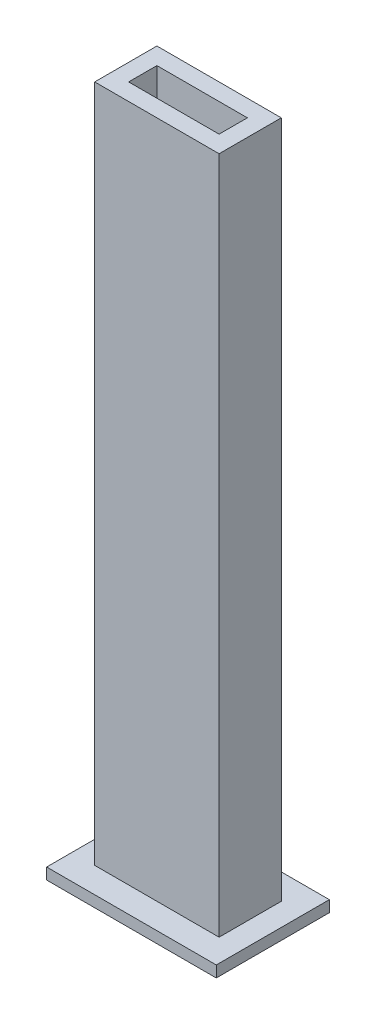
from build123d import *

# Parameters (mm, degrees)
CROQUIS1_W              = 30
CROQUIS1_H              = 20
SALIENTE_EXTRUIR1_DEPTH = 2
CROQUIS2_W              = 22
CROQUIS2_H              = 11
CROQUIS2_W_2            = 16
CROQUIS2_H_2            = 5
SALIENTE_EXTRUIR2_DEPTH = 120
CROQUIS3_W              = 16
CROQUIS3_H              = 5
CORTAR_EXTRUIR1_DEPTH   = 123


with BuildPart() as part:
    # Croquis1 → Saliente-Extruir1 (new body)
    with BuildSketch(Plane(origin=(0, 0, 0), x_dir=(1, 0, 0), z_dir=(0, 1, 0))):
        Rectangle(CROQUIS1_W, CROQUIS1_H)
    extrude(amount=SALIENTE_EXTRUIR1_DEPTH)

    # Croquis2 → Saliente-Extruir2 (add)
    with BuildSketch(Plane(origin=(0, 2, 0), x_dir=(1, 0, 0), z_dir=(0, 1, 0))):
        Rectangle(CROQUIS2_W, CROQUIS2_H)
        Rectangle(CROQUIS2_W_2, CROQUIS2_H_2, mode=Mode.SUBTRACT)
    extrude(amount=SALIENTE_EXTRUIR2_DEPTH)

    # Croquis3 → Cortar-Extruir1 (cut, through all)
    with BuildSketch(Plane(origin=(0, 122, 0), x_dir=(1, 0, 0), z_dir=(0, 1, 0))):
        Rectangle(CROQUIS3_W, CROQUIS3_H)
    extrude(amount=-CORTAR_EXTRUIR1_DEPTH, mode=Mode.SUBTRACT)


solid = part.part
